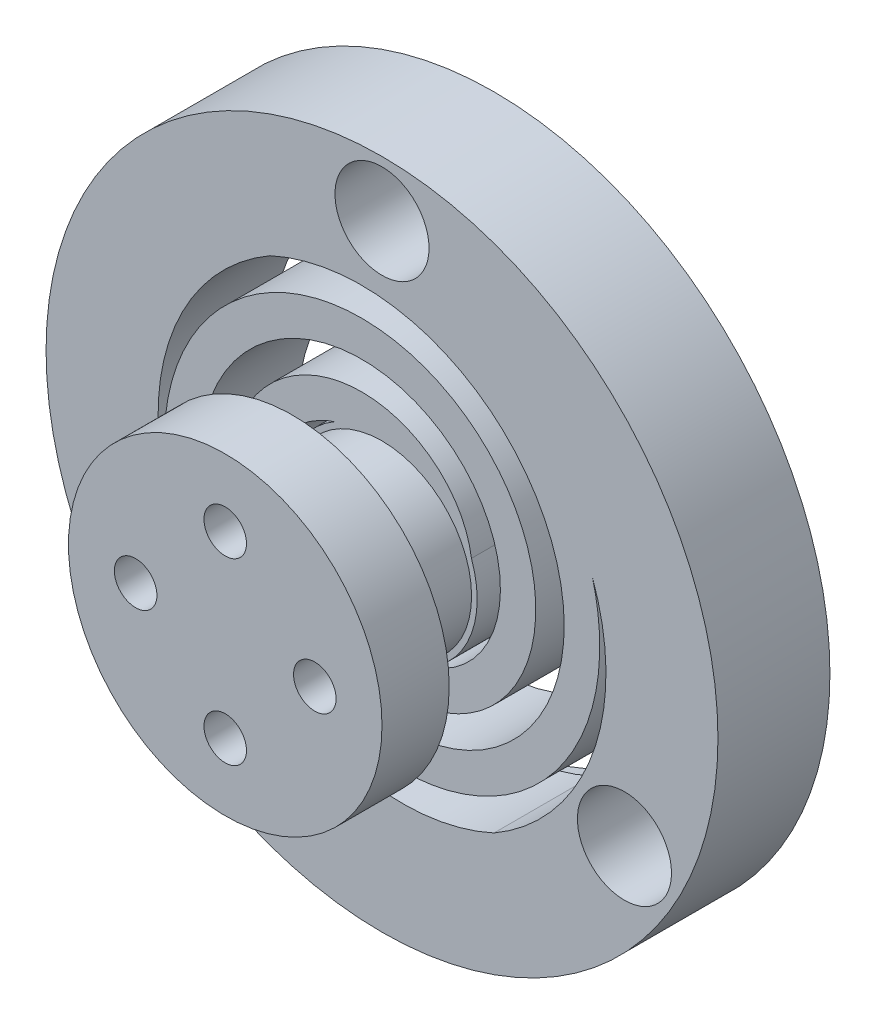
from build123d import *

# Parameters (mm, degrees)
SKETCH_1_R          = 15
SKETCH_1_R_2        = 10
SKETCH_1_R_3        = 1.1
EXTRUDE_1_DEPTH     = 2
SKETCH_2_R          = 15
SKETCH_2_R_2        = 10
SKETCH_2_R_3        = 2.1
EXTRUDE_2_DEPTH     = 3
EXTRUDE_3_DEPTH     = 4.4
SKETCH_9_R          = 3.25
CUT_EXTRUDE_1_DEPTH = 2.5
SKETCH_10_R         = 4
EXTRUDE_4_DEPTH     = 4
SKETCH_11_R         = 7
SKETCH_11_R_2       = 0.95
EXTRUDE_5_DEPTH     = 3


with BuildPart() as part:
    # Sketch 1 → Extrude 1 (new body)
    with BuildSketch(Plane.XY):
        Circle(SKETCH_1_R)
        Circle(SKETCH_1_R_2, mode=Mode.SUBTRACT)
        with Locations((0, 12.5)):
            Circle(SKETCH_1_R_3, mode=Mode.SUBTRACT)
        with Locations((10.825317547, -6.25)):
            Circle(SKETCH_1_R_3, mode=Mode.SUBTRACT)
        with Locations((-10.825317547, -6.25)):
            Circle(SKETCH_1_R_3, mode=Mode.SUBTRACT)
    extrude(amount=EXTRUDE_1_DEPTH)

    # Sketch 2 → Extrude 2 (add)
    with BuildSketch(Plane.XY.offset(2)):
        Circle(SKETCH_2_R)
        Circle(SKETCH_2_R_2, mode=Mode.SUBTRACT)
        with Locations((0, 12.5)):
            Circle(SKETCH_2_R_3, mode=Mode.SUBTRACT)
        with Locations((10.825317547, -6.25)):
            Circle(SKETCH_2_R_3, mode=Mode.SUBTRACT)
        with Locations((-10.825317547, -6.25)):
            Circle(SKETCH_2_R_3, mode=Mode.SUBTRACT)
    extrude(amount=EXTRUDE_2_DEPTH)

    # Sketch 8 → Extrude 3 (add)
    with BuildSketch(Plane.XY.offset(5)):
        with BuildLine():
            ThreePointArc((-2.125, 3.680607966), (-3.993693638, 1.453585609), (-3.993693638, -1.453585609))
            add(Edge.make_bspline(
                [(-9.396926208, -3.420201433), (-9.732062183, -2.149175506), (-9.806172611, -0.835010365), (-9.456725912, 1.676046677), (-9.033681598, 2.871966971), (-7.789656699, 4.972884513), (-6.969506065, 5.877213907), (-5.085556702, 7.278578571), (-4.022753032, 7.775339442), (-1.834341922, 8.316896689), (-0.709724019, 8.361833006), (1.425354593, 8.02880188), (2.434991624, 7.65134079), (4.194832357, 6.566362619), (4.944502403, 5.859612911), (6.091617732, 4.253128009), (6.488888652, 3.354278704), (6.901731194, 1.519508339), (6.917493401, 0.584437672), (6.600877847, -1.174662508), (6.268999982, -1.998016278), (5.34306854, -3.416780201), (4.749719757, -4.011790899), (3.420699316, -4.904656893), (2.685804375, -5.202437862), (1.204674755, -5.486565699), (0.459151326, -5.473153796), (-0.923970423, -5.172953815), (-1.561040931, -4.886659174), (-2.638728045, -4.11977446), (-3.079079395, -3.639826603), (-3.717696054, -2.588270623), (-3.915987072, -2.017330047), (-3.993693638, -1.453585609)],
                knots=[0, 0, 0, 0, 0.0625, 0.0625, 0.125, 0.125, 0.1875, 0.1875, 0.25, 0.25, 0.3125, 0.3125, 0.375, 0.375, 0.4375, 0.4375, 0.5, 0.5, 0.5625, 0.5625, 0.625, 0.625, 0.6875, 0.6875, 0.75, 0.75, 0.8125, 0.8125, 0.875, 0.875, 0.9375, 0.9375, 1, 1, 1, 1], degree=3))
            ThreePointArc((-9.396926208, -3.420201433), (-3.420201433, -9.396926208), (5, -8.660254038))
            add(Edge.make_bspline(
                [(5, -8.660254038), (3.806479564, -9.211009881), (2.525148685, -9.512196786), (-0.008440541, -9.604099447), (-1.259652992, -9.395151506), (-3.544675532, -8.534846644), (-4.577683795, -7.884191092), (-6.284902954, -6.272207574), (-6.958670832, -5.311811899), (-7.872014208, -3.250688101), (-8.111555691, -2.150958779), (-8.154336566, 0.009513438), (-7.957931589, 1.069357245), (-7.195029811, 2.990866525), (-6.629196056, 3.851873198), (-5.246311756, 5.260524443), (-4.430103363, 5.807843469), (-2.694896637, 6.533018535), (-1.776768874, 6.710914596), (0.010586336, 6.704573685), (0.879061498, 6.520711671), (2.437057517, 5.855212978), (3.126062601, 5.37420102), (4.236145931, 4.220415939), (4.657016106, 3.548394826), (5.194022862, 2.139105174), (5.310273501, 1.402578969), (5.254810803, -0.011659233), (5.083491754, -0.688765751), (4.515396145, -1.883248509), (4.119205984, -2.400252004), (3.194520122, -3.21176742), (2.666686289, -3.506188743), (2.125, -3.680607966)],
                knots=[0, 0, 0, 0, 0.0625, 0.0625, 0.125, 0.125, 0.1875, 0.1875, 0.25, 0.25, 0.3125, 0.3125, 0.375, 0.375, 0.4375, 0.4375, 0.5, 0.5, 0.5625, 0.5625, 0.625, 0.625, 0.6875, 0.6875, 0.75, 0.75, 0.8125, 0.8125, 0.875, 0.875, 0.9375, 0.9375, 1, 1, 1, 1], degree=3))
            ThreePointArc((2.125, -3.680607966), (3.993693638, -1.453585609), (3.993693638, 1.453585609))
            add(Edge.make_bspline(
                [(9.396926208, 3.420201433), (9.732062183, 2.149175506), (9.806172611, 0.835010365), (9.456725912, -1.676046677), (9.033681598, -2.871966971), (7.789656699, -4.972884513), (6.969506065, -5.877213907), (5.085556702, -7.278578571), (4.022753032, -7.775339442), (1.834341922, -8.316896689), (0.709724019, -8.361833006), (-1.425354593, -8.02880188), (-2.434991624, -7.65134079), (-4.194832357, -6.566362619), (-4.944502403, -5.859612911), (-6.091617732, -4.253128009), (-6.488888652, -3.354278704), (-6.901731194, -1.519508339), (-6.917493401, -0.584437672), (-6.600877847, 1.174662508), (-6.268999982, 1.998016278), (-5.34306854, 3.416780201), (-4.749719757, 4.011790899), (-3.420699316, 4.904656893), (-2.685804375, 5.202437862), (-1.204674755, 5.486565699), (-0.459151326, 5.473153796), (0.923970423, 5.172953815), (1.561040931, 4.886659174), (2.638728045, 4.11977446), (3.079079395, 3.639826603), (3.717696054, 2.588270623), (3.915987072, 2.017330047), (3.993693638, 1.453585609)],
                knots=[0, 0, 0, 0, 0.0625, 0.0625, 0.125, 0.125, 0.1875, 0.1875, 0.25, 0.25, 0.3125, 0.3125, 0.375, 0.375, 0.4375, 0.4375, 0.5, 0.5, 0.5625, 0.5625, 0.625, 0.625, 0.6875, 0.6875, 0.75, 0.75, 0.8125, 0.8125, 0.875, 0.875, 0.9375, 0.9375, 1, 1, 1, 1], degree=3))
            ThreePointArc((9.396926208, 3.420201433), (3.420201433, 9.396926208), (-5, 8.660254038))
            add(Edge.make_bspline(
                [(-5, 8.660254038), (-3.806479564, 9.211009881), (-2.525148685, 9.512196786), (0.008440541, 9.604099447), (1.259652992, 9.395151506), (3.544675532, 8.534846644), (4.577683795, 7.884191092), (6.284902954, 6.272207574), (6.958670832, 5.311811899), (7.872014208, 3.250688101), (8.111555691, 2.150958779), (8.154336566, -0.009513438), (7.957931589, -1.069357245), (7.195029811, -2.990866525), (6.629196056, -3.851873198), (5.246311756, -5.260524443), (4.430103363, -5.807843469), (2.694896637, -6.533018535), (1.776768874, -6.710914596), (-0.010586336, -6.704573685), (-0.879061498, -6.520711671), (-2.437057517, -5.855212978), (-3.126062601, -5.37420102), (-4.236145931, -4.220415939), (-4.657016106, -3.548394826), (-5.194022862, -2.139105174), (-5.310273501, -1.402578969), (-5.254810803, 0.011659233), (-5.083491754, 0.688765751), (-4.515396145, 1.883248509), (-4.119205984, 2.400252004), (-3.194520122, 3.21176742), (-2.666686289, 3.506188743), (-2.125, 3.680607966)],
                knots=[0, 0, 0, 0, 0.0625, 0.0625, 0.125, 0.125, 0.1875, 0.1875, 0.25, 0.25, 0.3125, 0.3125, 0.375, 0.375, 0.4375, 0.4375, 0.5, 0.5, 0.5625, 0.5625, 0.625, 0.625, 0.6875, 0.6875, 0.75, 0.75, 0.8125, 0.8125, 0.875, 0.875, 0.9375, 0.9375, 1, 1, 1, 1], degree=3))
        make_face()
    extrude(amount=-EXTRUDE_3_DEPTH)

    # Sketch 9 → Cut-Extrude 1 (cut)
    with BuildSketch(Plane(origin=(0, 0, 0.6), x_dir=(-1, 0, 0), z_dir=(0, 0, -1))):
        Circle(SKETCH_9_R)
    extrude(amount=-CUT_EXTRUDE_1_DEPTH, mode=Mode.SUBTRACT)

    # Sketch 10 → Extrude 4 (add)
    with BuildSketch(Plane.XY.offset(5)):
        Circle(SKETCH_10_R)
    extrude(amount=EXTRUDE_4_DEPTH)

    # Sketch 11 → Extrude 5 (add)
    with BuildSketch(Plane.XY.offset(9)):
        Circle(SKETCH_11_R)
        with Locations((0, 4)):
            Circle(SKETCH_11_R_2, mode=Mode.SUBTRACT)
        with Locations((4, 0)):
            Circle(SKETCH_11_R_2, mode=Mode.SUBTRACT)
        with Locations((0, -4)):
            Circle(SKETCH_11_R_2, mode=Mode.SUBTRACT)
        with Locations((-4, 0)):
            Circle(SKETCH_11_R_2, mode=Mode.SUBTRACT)
    extrude(amount=EXTRUDE_5_DEPTH)


solid = part.part
